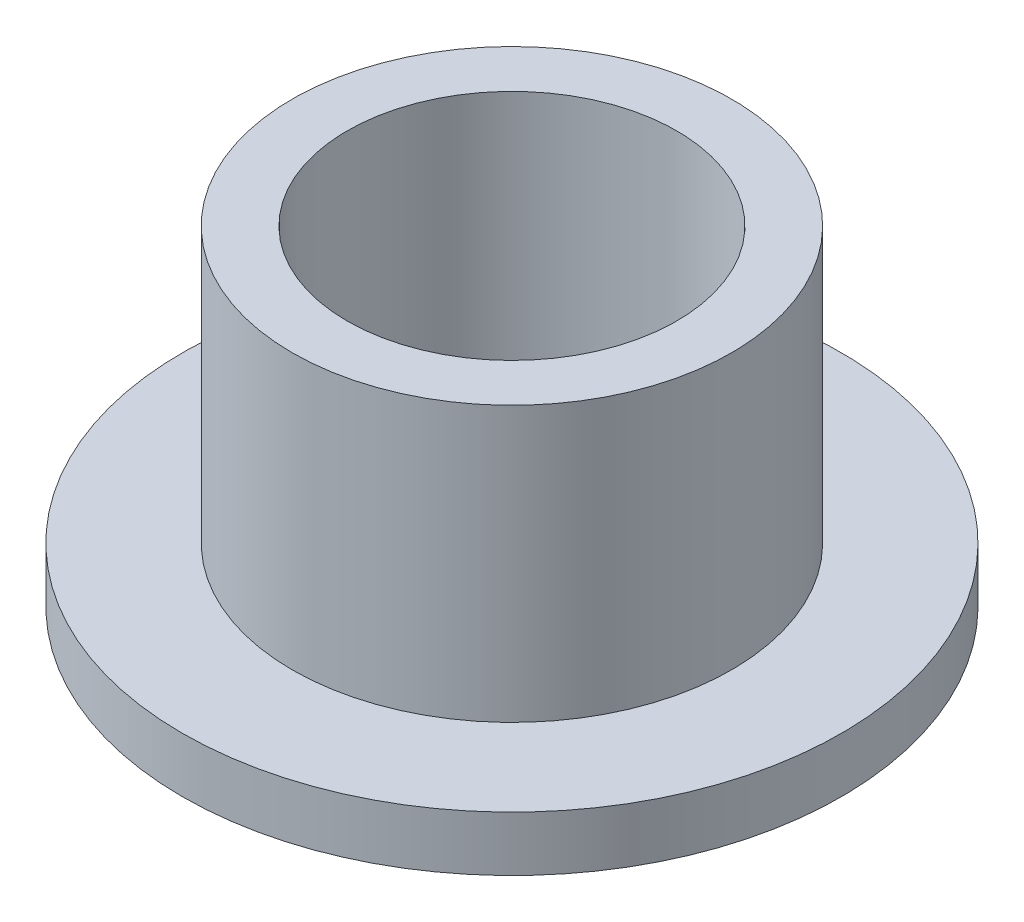
from build123d import *

# Parameters (mm, degrees)
SKETCH2_R           = 4
SKETCH2_R_2         = 3
BOSS_EXTRUDE1_DEPTH = 6
SKETCH3_R           = 6
SKETCH3_R_2         = 4
BOSS_EXTRUDE2_DEPTH = 1


with BuildPart() as part:
    # Sketch2 → Boss-Extrude1 (new body)
    with BuildSketch(Plane(origin=(0, 0, 0), x_dir=(1, 0, 0), z_dir=(0, 1, 0))):
        Circle(SKETCH2_R)
        Circle(SKETCH2_R_2, mode=Mode.SUBTRACT)
    extrude(amount=BOSS_EXTRUDE1_DEPTH)

    # Sketch3 → Boss-Extrude2 (add)
    with BuildSketch(Plane(origin=(0, 0, 0), x_dir=(1, 0, 0), z_dir=(0, 1, 0))):
        Circle(SKETCH3_R)
        Circle(SKETCH3_R_2, mode=Mode.SUBTRACT)
    extrude(amount=BOSS_EXTRUDE2_DEPTH)


solid = part.part
